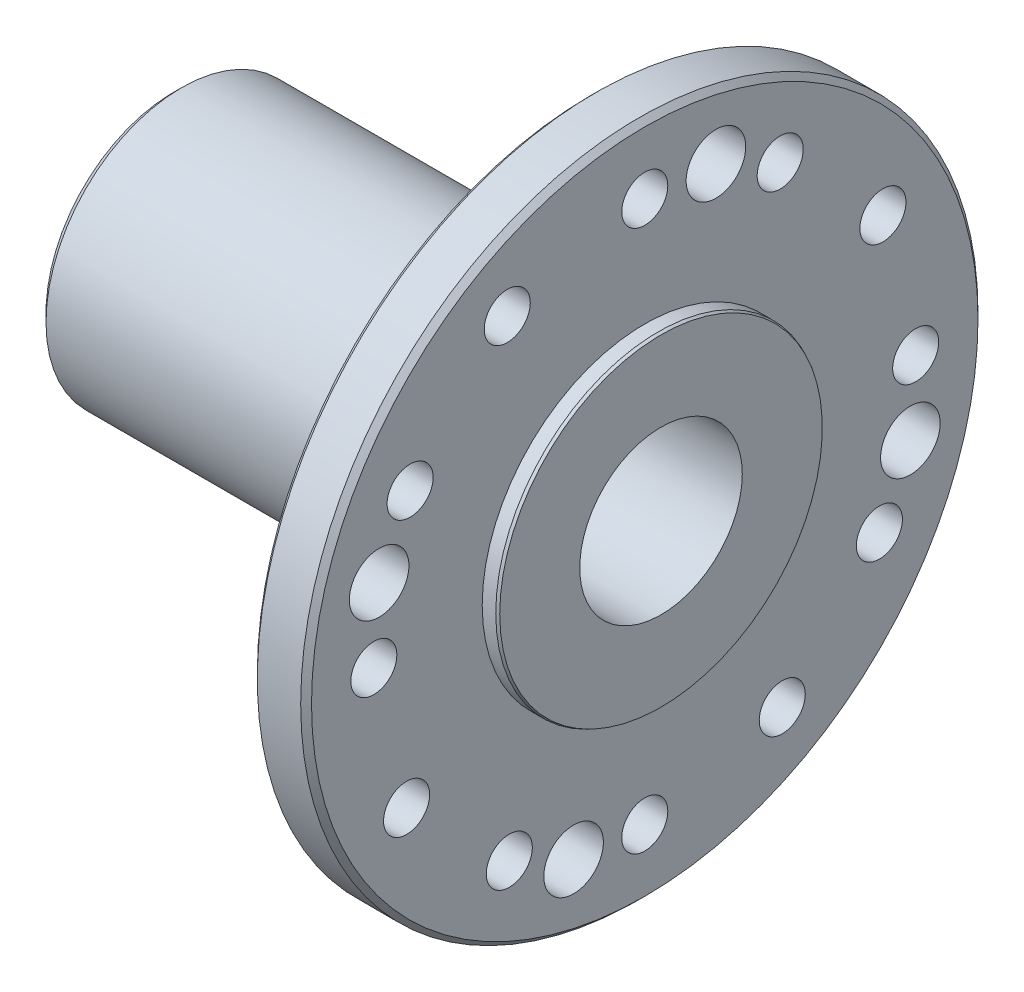
from build123d import *

# Parameters (mm, degrees)
FASE6_SIZE                       = 1
FASE7_SIZE                       = 1
FASE8_SIZE                       = 1.5
FASE9_SIZE                       = 0.5
FASE9_SIZE2                      = 0.233153829
SKIZZE18_R                       = 15
SCHNITT_LINEAR_AUSTRAGEN5_DEPTH  = 60
SKIZZE19_R                       = 11.075
SCHNITT_LINEAR_AUSTRAGEN6_DEPTH  = 31
SKIZZE21_R                       = 4.25
SCHNITT_LINEAR_AUSTRAGEN7_DEPTH  = 88
SKIZZE22_R                       = 4.25
SCHNITT_LINEAR_AUSTRAGEN8_DEPTH  = 88
SKIZZE23_R                       = 5.5
SCHNITT_LINEAR_AUSTRAGEN9_DEPTH  = 88
SKIZZE36_R                       = 4.25
SCHNITT_LINEAR_AUSTRAGEN10_DEPTH = 88
KREISMUSTER42_COUNT              = 4
AUFSATZ_LINEAR_AUSTRAGEN8_DEPTH  = 30
KREISMUSTER41_COUNT              = 28


with BuildPart() as part:
    # Skizze17 → Rotation2 (revolve)
    with BuildSketch(Plane.XY, mode=Mode.PRIVATE) as rotation2_sk:
        with BuildLine():
            Line((0, 0), (0, -25))
            Line((0, -25), (72, -25))
            ThreePointArc((72, -25), (75.535533906, -26.464466094), (77, -30))
            Line((77, -30), (77, -62.5))
            Line((77, -62.5), (87, -62.5))
            Line((87, -62.5), (87, -30))
            Line((87, -30), (90, -30))
            Line((90, -30), (90, 0))
            Line((90, 0), (0, 0))
        make_face()
    revolve(rotation2_sk.sketch.rotate(Axis((90, 0, 0), (-1, 0, 0)), 270), axis=Axis((90, 0, 0), (-1, 0, 0)))  # turned: the seam where the file's is

    # Fase6
    fase6_edges = [part.edges().sort_by_distance(p)[0] for p in [
        (77, 0, 62.5),
    ]]
    chamfer(fase6_edges, length=FASE6_SIZE)

    # Fase7
    fase7_edges = [part.edges().sort_by_distance(p)[0] for p in [
        (87, 0, 62.5),
    ]]
    chamfer(fase7_edges, length=FASE7_SIZE)

    # Fase8
    fase8_edges = [part.edges().sort_by_distance(p)[0] for p in [
        (0, 0, 25),
    ]]
    chamfer(fase8_edges, length=FASE8_SIZE)

    # Fase9
    fase9_edges = [part.edges().sort_by_distance(p)[0] for p in [
        (90, 0, 30),
    ]]
    fase9_side = [part.faces().sort_by_distance(p)[0] for p in [
        (88.5, 0, 30),
    ]]
    chamfer(fase9_edges, length=FASE9_SIZE, length2=FASE9_SIZE2, reference=fase9_side[0])

    # Skizze18 → Schnitt-Linear austragen5 (cut)
    with BuildSketch(Plane(origin=(90, 0, 0), x_dir=(0, 0, -1), z_dir=(1, 0, 0))):
        Circle(SKIZZE18_R)
    extrude(amount=-SCHNITT_LINEAR_AUSTRAGEN5_DEPTH, mode=Mode.SUBTRACT)

    # Skizze19 → Schnitt-Linear austragen6 (cut, through all)
    with BuildSketch(Plane(origin=(30, 0, 0), x_dir=(0, 0, -1), z_dir=(1, 0, 0))):
        Circle(SKIZZE19_R)
    extrude(amount=-SCHNITT_LINEAR_AUSTRAGEN6_DEPTH, mode=Mode.SUBTRACT)

    # Skizze21 → Schnitt-Linear austragen7 (cut, through all)
    with BuildSketch(Plane(origin=(87, 0, 0), x_dir=(0, 0, -1), z_dir=(1, 0, 0))):
        with Locations((0, 50)):
            Circle(SKIZZE21_R)
    schnitt_linear_austragen7 = extrude(amount=-SCHNITT_LINEAR_AUSTRAGEN7_DEPTH, mode=Mode.SUBTRACT)

    # Skizze22 → Schnitt-Linear austragen8 (cut, through all)
    with BuildSketch(Plane(origin=(87, 0, 0), x_dir=(0, 0, -1), z_dir=(1, 0, 0))):
        with Locations((25, 43.301270189)):
            Circle(SKIZZE22_R)
    schnitt_linear_austragen8 = extrude(amount=-SCHNITT_LINEAR_AUSTRAGEN8_DEPTH, mode=Mode.SUBTRACT)

    # Skizze23 → Schnitt-Linear austragen9 (cut, through all)
    with BuildSketch(Plane(origin=(87, 0, 0), x_dir=(0, 0, -1), z_dir=(1, 0, 0))):
        with Locations((13.135066539, 49.020735684)):
            Circle(SKIZZE23_R)
    schnitt_linear_austragen9 = extrude(amount=-SCHNITT_LINEAR_AUSTRAGEN9_DEPTH, mode=Mode.SUBTRACT)

    # Skizze36 → Schnitt-Linear austragen10 (cut, through all)
    with BuildSketch(Plane(origin=(87, 0, 0), x_dir=(0, 0, -1), z_dir=(1, 0, 0))):
        with Locations((43.950789242, 25.375)):
            Circle(SKIZZE36_R)
    schnitt_linear_austragen10 = extrude(amount=-SCHNITT_LINEAR_AUSTRAGEN10_DEPTH, mode=Mode.SUBTRACT)

    # Kreismuster42: Schnitt-Linear austragen7, Schnitt-Linear austragen8, Schnitt-Linear austragen9, Schnitt-Linear austragen10 ×4 about axis
    kreismuster42_axis = Axis((0, 0, 0), (1, 0, 0))
    add([schnitt_linear_austragen7.rotate(kreismuster42_axis, i * 360 / KREISMUSTER42_COUNT) for i in range(1, KREISMUSTER42_COUNT)], mode=Mode.SUBTRACT)
    add([schnitt_linear_austragen8.rotate(kreismuster42_axis, i * 360 / KREISMUSTER42_COUNT) for i in range(1, KREISMUSTER42_COUNT)], mode=Mode.SUBTRACT)
    add([schnitt_linear_austragen9.rotate(kreismuster42_axis, i * 360 / KREISMUSTER42_COUNT) for i in range(1, KREISMUSTER42_COUNT)], mode=Mode.SUBTRACT)
    add([schnitt_linear_austragen10.rotate(kreismuster42_axis, i * 360 / KREISMUSTER42_COUNT) for i in range(1, KREISMUSTER42_COUNT)], mode=Mode.SUBTRACT)

    # Skizze34 → Aufsatz-Linear austragen8 (add)
    with BuildSketch(Plane.ZY):
        Polygon((-0.998723447, 11.075), (-0.55, 10.175), (0.55, 10.175), (0.998723447, 11.075), align=None)
    aufsatz_linear_austragen8 = extrude(amount=-AUFSATZ_LINEAR_AUSTRAGEN8_DEPTH)

    # Kreismuster41: Aufsatz-Linear austragen8 ×28 about axis
    kreismuster41_axis = Axis((0, 0, 0), (1, 0, 0))
    for i in range(1, KREISMUSTER41_COUNT):
        add(aufsatz_linear_austragen8.rotate(kreismuster41_axis, i * 360 / KREISMUSTER41_COUNT))

    # Skizze35 → Schnitt-Rotation1 (revolve, cut)
    with BuildSketch(Plane(origin=(0, 0, 0), x_dir=(1, 0, 0), z_dir=(0, 1, 0))):
        Polygon((0, 11.25), (11.25, 0), (0, 0), align=None)
        Polygon((18.75, 0), (30, 0), (30, 11.25), align=None)
    revolve(axis=Axis((0, 0, 0), (1, 0, 0)), mode=Mode.SUBTRACT)


solid = part.part
